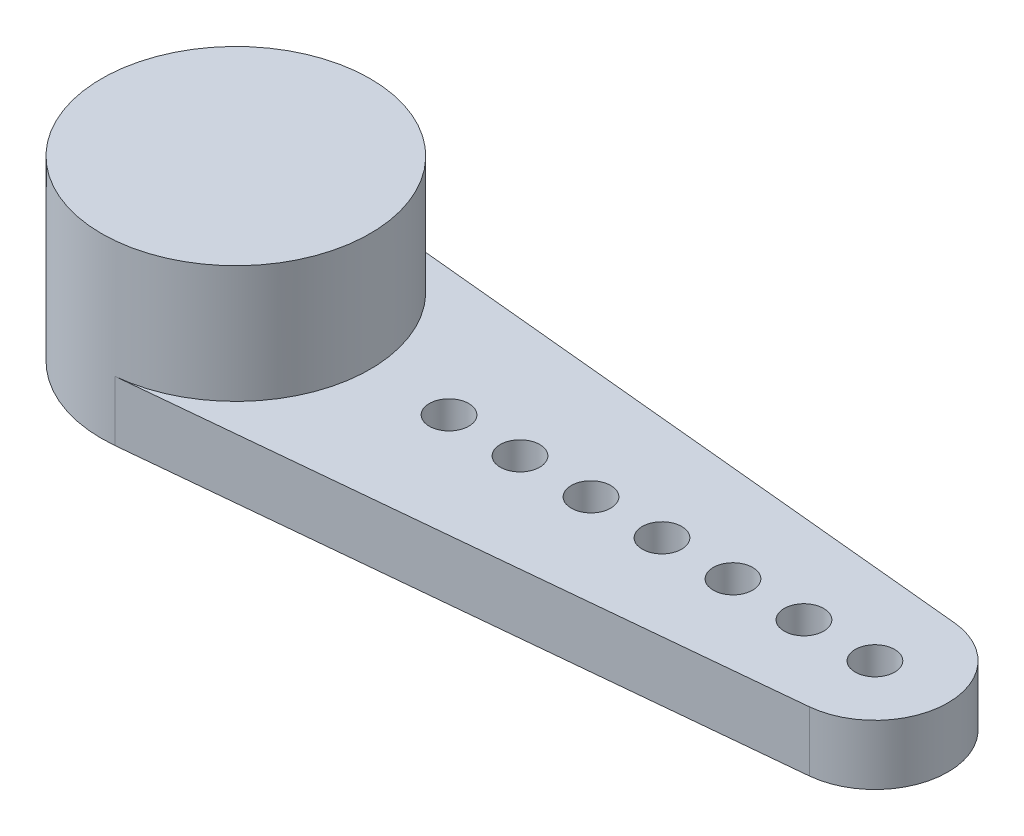
from build123d import *

# Parameters (mm, degrees)
SKETCH_1_R          = 3.405
EXTRUDE_1_DEPTH     = 4.5
EXTRUDE_2_DEPTH     = 1.52
SKETCH_3_R          = 0.5
CUT_EXTRUDE_1_DEPTH = 1.52


with BuildPart() as part:
    # 草图1 → 凸台-拉伸1 (new body)
    with BuildSketch(Plane(origin=(0, 0, 0), x_dir=(1, 0, 0), z_dir=(0, 1, 0))):
        Circle(SKETCH_1_R)
    extrude(amount=EXTRUDE_1_DEPTH)

    # 草图2 → 凸台-拉伸2 (add)
    with BuildSketch(Plane.XZ):
        with BuildLine():
            Line((0.326737118, 3.389287219), (16.38252237, 1.841462953))
            ThreePointArc((16.38252237, 1.841462953), (18.055, 0), (16.38252237, -1.841462953))
            Line((16.38252237, -1.841462953), (0.326737118, -3.389287219))
            ThreePointArc((0.326737118, -3.389287219), (-3.405, 0), (0.326737118, 3.389287219))
        make_face()
    extrude(amount=-EXTRUDE_2_DEPTH)

    # 草图3 → 切除-拉伸1 (cut)
    with BuildSketch(Plane.XZ):
        with Locations((16.205, 0)):
            Circle(SKETCH_3_R)
        with Locations((14.405, 0)):
            Circle(SKETCH_3_R)
        with Locations((12.605, 0)):
            Circle(SKETCH_3_R)
        with Locations((10.805, 0)):
            Circle(SKETCH_3_R)
        with Locations((9.005, 0)):
            Circle(SKETCH_3_R)
        with Locations((7.205, 0)):
            Circle(SKETCH_3_R)
        with Locations((5.405, 0)):
            Circle(SKETCH_3_R)
    extrude(amount=-CUT_EXTRUDE_1_DEPTH, mode=Mode.SUBTRACT)


solid = part.part
